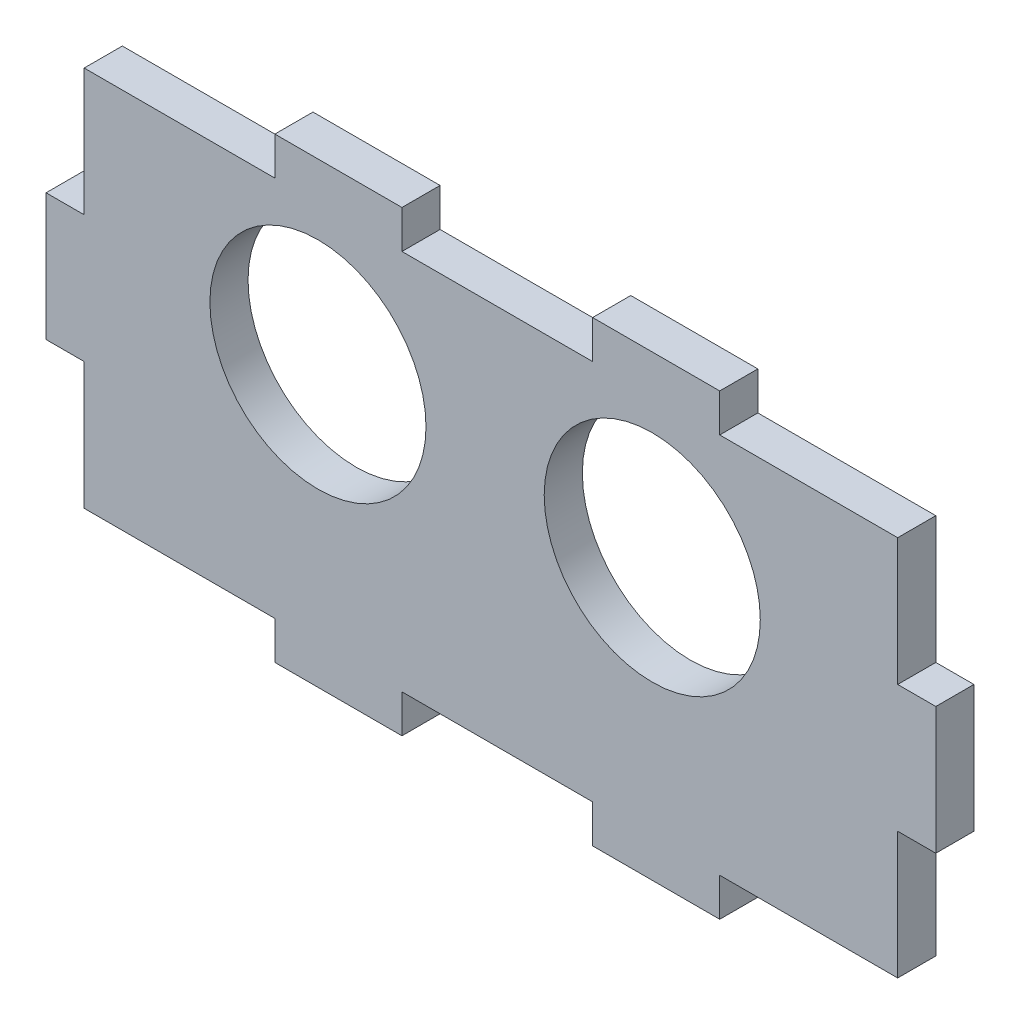
from build123d import *

# Parameters (mm, degrees)
ESQUISSE1_R        = 8.5
BOSS_EXTRU_1_DEPTH = 3


with BuildPart() as part:
    # Esquisse1 → Boss.-Extru.1 (new body)
    with BuildSketch(Plane.XY):
        Polygon((-38.901238907, 0), (-23.901238907, 0), (-23.901238907, 3), (-13.901238907, 3), (-13.901238907, 0), (1.098761093, 0), (1.098761093, 3), (11.098761093, 3), (11.098761093, 0), (25.098761093, 0), (25.098761093, -10), (28.098761093, -10), (28.098761093, -20), (25.098761093, -20), (25.098761093, -30), (11.098761093, -30), (11.098761093, -33), (1.098761093, -33), (1.098761093, -30), (-13.901238907, -30), (-13.901238907, -33), (-23.901238907, -33), (-23.901238907, -30), (-38.901238907, -30), (-38.901238907, -20), (-41.901238907, -20), (-41.901238907, -10), (-38.901238907, -10), align=None)
        with Locations((-20.510522939, -11)):
            Circle(ESQUISSE1_R, mode=Mode.SUBTRACT)
        with Locations((5.789477061, -11)):
            Circle(ESQUISSE1_R, mode=Mode.SUBTRACT)
    extrude(amount=BOSS_EXTRU_1_DEPTH)


solid = part.part
